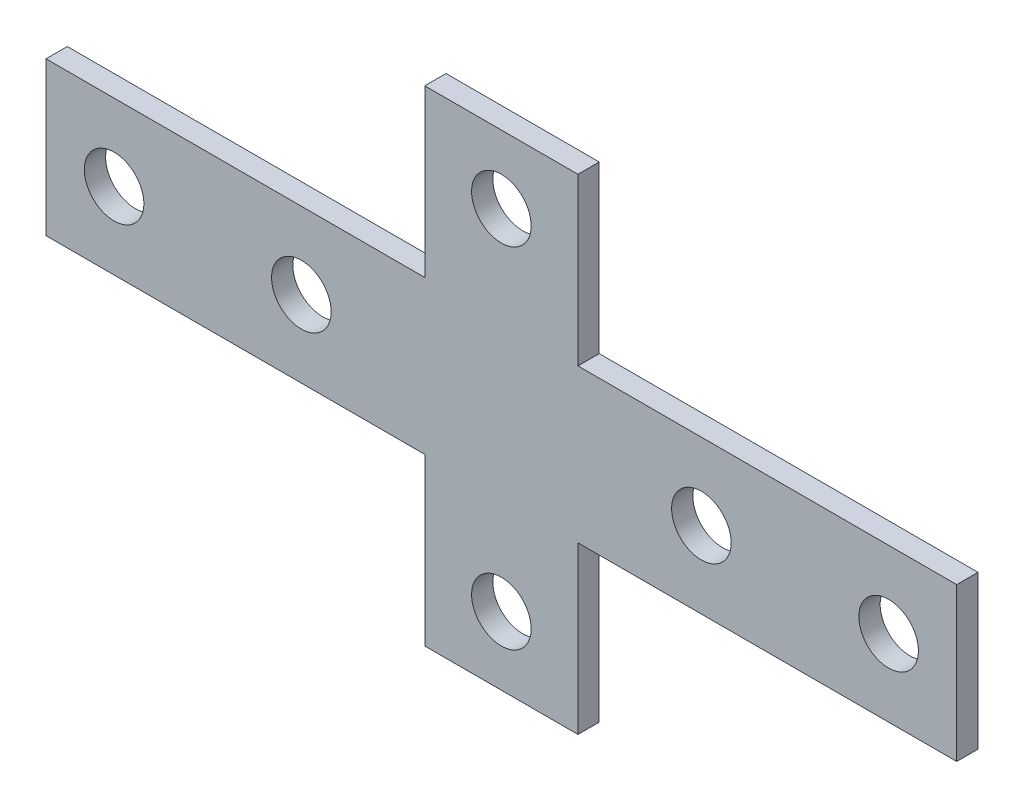
from build123d import *

# Parameters (mm, degrees)
SKETCH_1_R      = 3.5
EXTRUDE_1_DEPTH = 2.5


with BuildPart() as part:
    # Эскиз1 → Бобышка-Вытянуть1 (new body)
    with BuildSketch(Plane.XY):
        Polygon((9, -9), (53.5, -9), (53.5, 9), (9, 9), (9, 28.5), (-9, 28.5), (-9, 9), (-53.5, 9), (-53.5, -9), (-9, -9), (-9, -28.5), (9, -28.5), align=None)
        with Locations((0, 20.5)):
            Circle(SKETCH_1_R, mode=Mode.SUBTRACT)
        with Locations((0, -20.5)):
            Circle(SKETCH_1_R, mode=Mode.SUBTRACT)
        with Locations((-45.5, 0)):
            Circle(SKETCH_1_R, mode=Mode.SUBTRACT)
        with Locations((-23.5, 0)):
            Circle(SKETCH_1_R, mode=Mode.SUBTRACT)
        with Locations(Location((23.5, 0, 0), (0, 0, 180))):  # turned: the seam where the file's is
            Circle(SKETCH_1_R, mode=Mode.SUBTRACT)
        with Locations(Location((45.5, 0, 0), (0, 0, 180))):  # turned: the seam where the file's is
            Circle(SKETCH_1_R, mode=Mode.SUBTRACT)
    extrude(amount=EXTRUDE_1_DEPTH)


solid = part.part
